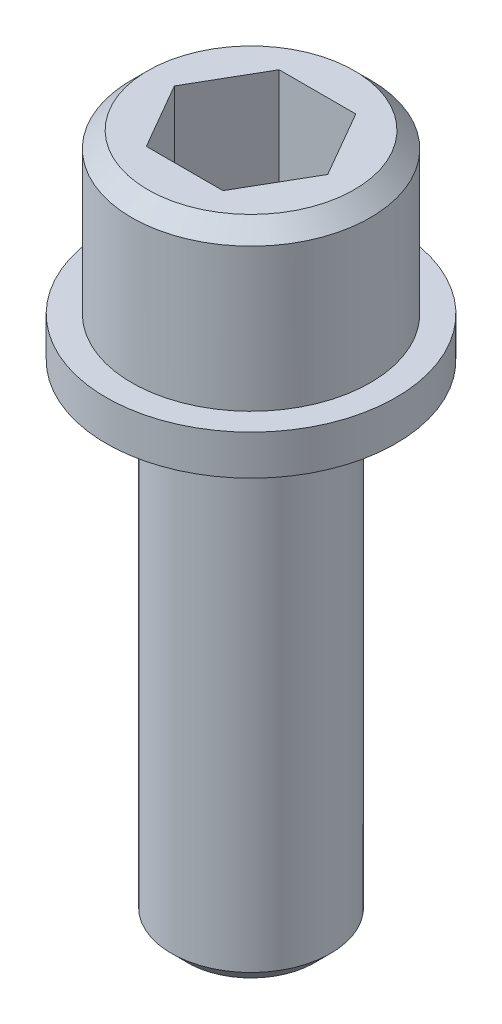
from build123d import *

# Parameters (mm, degrees)
CUT_EXTRUDE1_DEPTH = 6.35
CHAMFER1_SIZE      = 0.9652
CHAMFER2_SIZE      = 0.9652


with BuildPart() as part:
    # Sketch2 → Revolve1 (revolve)
    with BuildSketch(Plane.XY):
        Polygon((0, 41.275), (7.14375, 41.275), (7.14375, 31.75), (8.6741, 31.75), (8.6741, 29.3624), (4.7625, 29.3624), (4.7625, 0), (0, 0), align=None)
    revolve(axis=Axis((0, 0, 0), (0, 1, 0)))

    # Sketch3 → Cut-Extrude1 (cut)
    with BuildSketch(Plane(origin=(0, 41.275, 0), x_dir=(1, 0, 0), z_dir=(0, 1, 0))):
        Polygon((4.59005011, 0), (2.295025055, 3.9751), (-2.295025055, 3.9751), (-4.59005011, 0), (-2.295025055, -3.9751), (2.295025055, -3.9751), align=None)
    extrude(amount=-CUT_EXTRUDE1_DEPTH, mode=Mode.SUBTRACT)

    # Chamfer1
    chamfer1_edges = [part.edges().sort_by_distance(p)[0] for p in [
        (-7.14375, 41.275, 0),
    ]]
    chamfer(chamfer1_edges, length=CHAMFER1_SIZE)

    # Chamfer2
    chamfer2_edges = [part.edges().sort_by_distance(p)[0] for p in [
        (-4.7625, 0, 0),
    ]]
    chamfer(chamfer2_edges, length=CHAMFER2_SIZE)


solid = part.part
